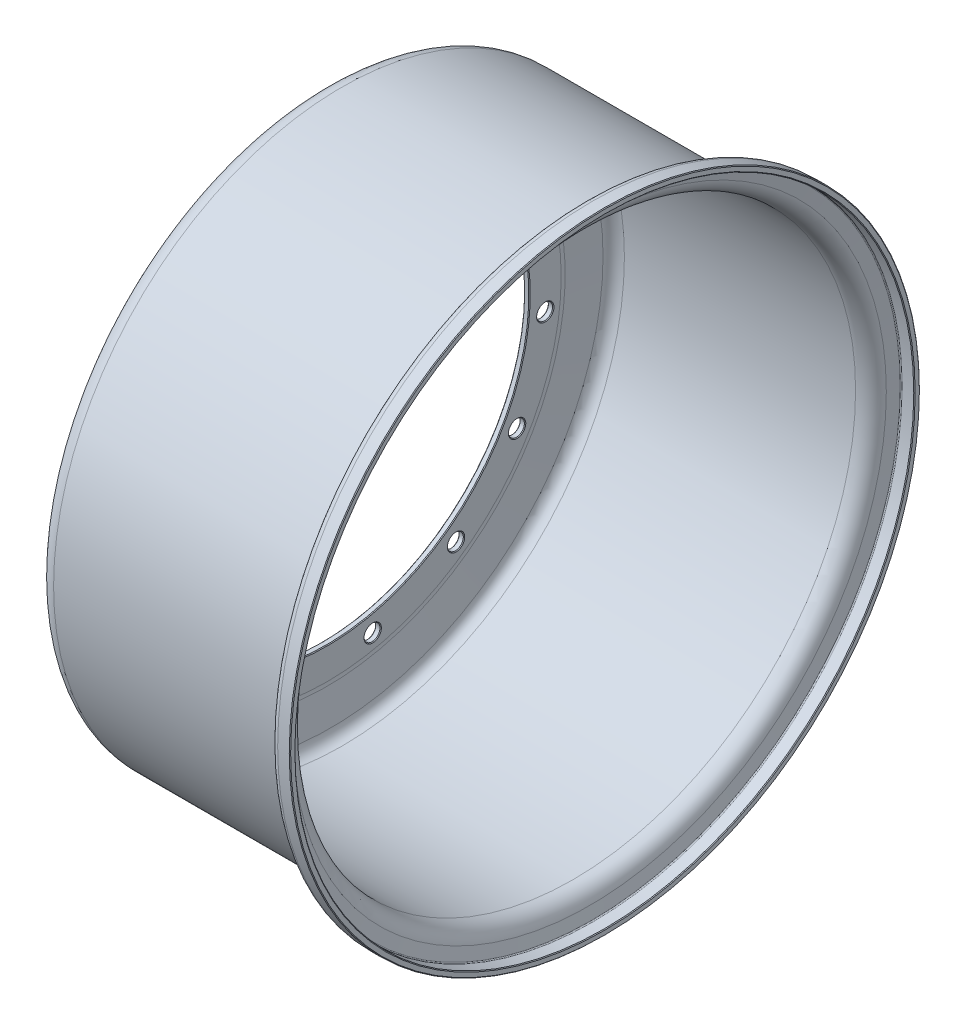
from build123d import *

# Parameters (mm, degrees)
SKETCH2_R                   = 4.49834
MOUNTING_HOLE_DEPTH         = 161.020560587
MOUNTING_HOLE_PATTERN_COUNT = 15
EDGE_CHAMFER_SIZE           = 0.39624


with BuildPart() as part:
    # Sketch1 → Outer Rim (revolve)
    with BuildSketch(Plane.XY):
        with BuildLine():
            Line((0, 114.3), (0, 132.12064))
            ThreePointArc((0, 132.12064), (0.02969217, 133.34873), (0.118699294, 134.573950146))
            Line((0.118699294, 134.573950146), (2.007086476, 154.043123701))
            ThreePointArc((2.007086476, 154.043123701), (5.085877569, 160.176614491), (11.487947569, 162.648893514))
            Line((11.487947569, 162.648893514), (141.944887569, 162.648893514))
            ThreePointArc((141.944887569, 162.648893514), (146.046987569, 164.15167281), (148.207524489, 167.948730913))
            Line((148.207524489, 167.948730913), (149.326238435, 174.619596349))
            ThreePointArc((149.326238435, 174.619596349), (150.622560587, 176.89783121), (153.083820587, 177.799498788))
            Line((153.083820587, 177.799498788), (160.020560587, 177.799498788))
            Line((160.020560587, 177.799498788), (160.020560587, 174.624498788))
            Line((160.020560587, 174.624498788), (153.083820587, 174.624498788))
            ThreePointArc((153.083820587, 174.624498788), (152.673581252, 174.474210111), (152.45751211, 174.094477147))
            Line((152.45751211, 174.094477147), (151.338798163, 167.423611711))
            ThreePointArc((151.338798163, 167.423611711), (148.098008234, 161.728051711), (141.944887569, 159.473893514))
            Line((141.944887569, 159.473893514), (11.487947569, 159.473893514))
            ThreePointArc((11.487947569, 159.473893514), (7.21982168, 157.825676906), (5.167256187, 153.736607148))
            Line((5.167256187, 153.736607148), (3.278869005, 134.267433592))
            ThreePointArc((3.278869005, 134.267433592), (3.20098243, 133.195292443), (3.175, 132.12064))
            Line((3.175, 132.12064), (3.175, 114.3))
            Line((3.175, 114.3), (0, 114.3))
        make_face()
    revolve(axis=Axis((-6.731028029, 0, 0), (1, 0, 0)))

    # Sketch2 → Mounting Hole (cut, through all)
    with BuildSketch(Plane.ZY):
        with Locations((0, 123.825)):
            Circle(SKETCH2_R)
    mounting_hole = extrude(amount=-MOUNTING_HOLE_DEPTH, mode=Mode.SUBTRACT)

    # Mounting Hole Pattern: Mounting Hole ×15 about axis
    mounting_hole_pattern_axis = Axis((0, 0, 0), (1, 0, 0))
    for i in range(1, MOUNTING_HOLE_PATTERN_COUNT):
        add(mounting_hole.rotate(mounting_hole_pattern_axis, i * 360 / MOUNTING_HOLE_PATTERN_COUNT), mode=Mode.SUBTRACT)

    # Edge Chamfer
    edge_chamfer_edges = [part.edges().sort_by_distance(p)[0] for p in [
        (3.175, 79.512179238, -95.029884987),
        (0, 79.512179238, -95.029884987),
        (3.175, 111.290126582, -54.473602903),
        (0, 111.290126582, -54.473602903),
        (3.175, -114.3, 0),
        (160.020560587, -174.624498788, 0),
        (160.020560587, -177.799498788, 0),
        (0, -114.3, 0),
        (3.175, 123.825, -4.49834),
        (0, 123.825, -4.49834),
        (3.175, 114.949406004, 46.254726755),
        (0, 114.949406004, 46.254726755),
        (3.175, 86.198015427, 89.009931043),
        (0, 86.198015427, 89.009931043),
        (3.175, 42.542204898, 116.374509624),
        (0, 42.542204898, 116.374509624),
        (3.175, -8.469539341, 123.616878261),
        (0, -8.469539341, 123.616878261),
        (3.175, -58.016823285, 109.484765624),
        (0, -58.016823285, 109.484765624),
        (3.175, -97.532471417, 76.421742372),
        (0, -97.532471417, 76.421742372),
        (3.175, -120.183869186, 30.144705594),
        (0, -120.183869186, 30.144705594),
        (3.175, -122.054384136, -21.344624637),
        (0, -122.054384136, -21.344624637),
        (3.175, -102.82058724, -69.143275359),
        (0, -102.82058724, -69.143275359),
        (3.175, -65.808176715, -104.986425624),
        (0, -65.808176715, -104.986425624),
        (3.175, -17.416934587, -122.676469127),
        (0, -17.416934587, -122.676469127),
        (3.175, 33.985853759, -119.154636637),
        (0, 33.985853759, -119.154636637),
    ]]
    chamfer(edge_chamfer_edges, length=EDGE_CHAMFER_SIZE)


solid = part.part
